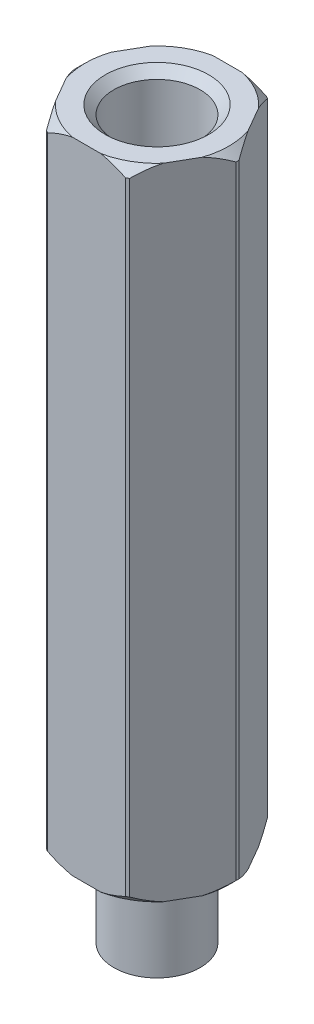
from build123d import *

# Parameters (mm, degrees)
SKETCH3_R         = 1.5
EXTRUDE1_DEPTH    = 12
CHAMFER1_SIZE     = 0.3
SKETCH4_OUTSIDE_W = 12.89
SKETCH4_OUTSIDE_H = 12.89
EXTRUDE2_DEPTH    = 26.24


with BuildPart() as part:
    # Sketch2 → Revolve3 (revolve)
    with BuildSketch(Plane.XY):
        Polygon((0, 0), (-1.5, 0), (-1.5, 3), (-2.8, 3), (-2.8, 25.24), (0, 25.24), align=None)
    revolve(axis=Axis((0, 33.398198685, 0), (0, -1, 0)))

    # Sketch3 → Extrude1 (cut)
    with BuildSketch(Plane(origin=(0, 25.24, 0), x_dir=(1, 0, 0), z_dir=(0, 1, 0))):
        Circle(SKETCH3_R)
    extrude(amount=-EXTRUDE1_DEPTH, mode=Mode.SUBTRACT)

    # Chamfer1
    chamfer1_edges = [part.edges().sort_by_distance(p)[0] for p in [
        (-1.5, 25.24, 0),
        (2.8, 25.24, 0),
        (2.8, 3, 0),
    ]]
    chamfer(chamfer1_edges, length=CHAMFER1_SIZE)

    # Sketch4 outside → Extrude2 (cut, through all)
    with BuildSketch(Plane(origin=(0, 25.24, 0), x_dir=(1, 0, 0), z_dir=(0, 1, 0))):
        Rectangle(SKETCH4_OUTSIDE_W, SKETCH4_OUTSIDE_H)
        Polygon((2.829016319, 0), (1.41450816, 2.45), (-1.41450816, 2.45), (-2.829016319, 0), (-1.41450816, -2.45), (1.41450816, -2.45), align=None, mode=Mode.SUBTRACT)
    extrude(amount=-EXTRUDE2_DEPTH, mode=Mode.SUBTRACT)


solid = part.part
